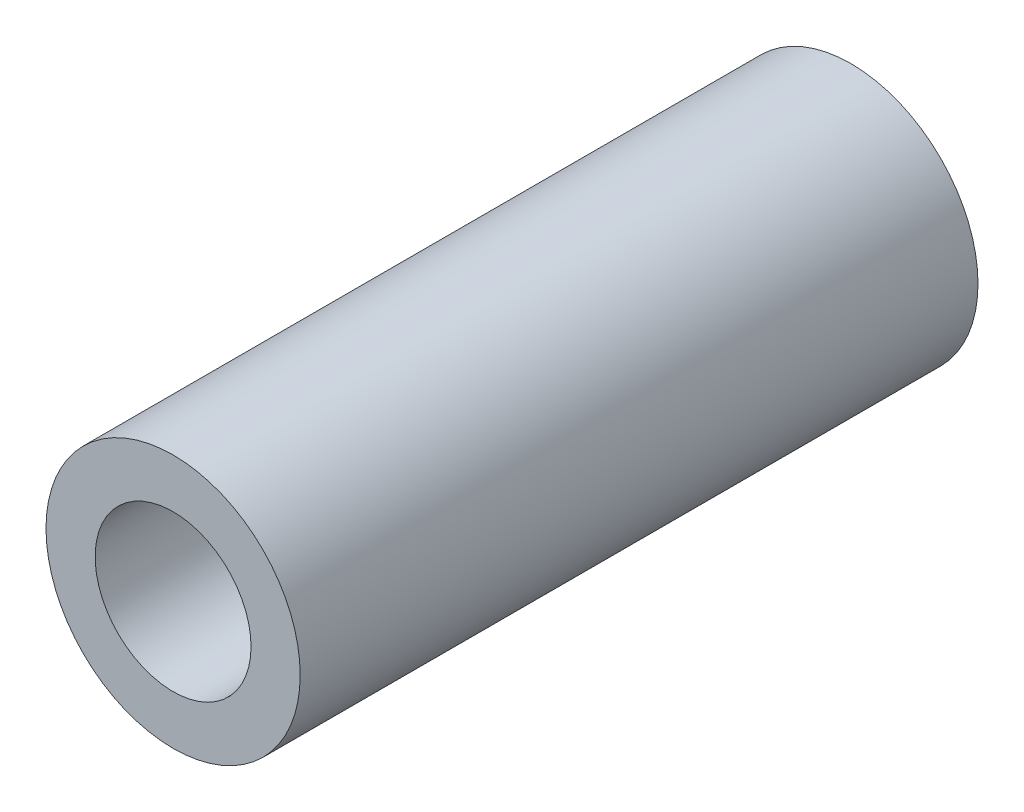
from build123d import *

# Parameters (mm, degrees)
SKETCH1_R           = 2.38125
SKETCH1_R_2         = 1.4605
EXTRUDE1_DEPTH      = 6.35
EXTRUDE1_DEPTH_BACK = 6.35


with BuildPart() as part:
    # Sketch1 → Extrude1 (new body, two sides)
    with BuildSketch(Plane.XY) as extrude1_sk:
        Circle(SKETCH1_R)
        Circle(SKETCH1_R_2, mode=Mode.SUBTRACT)
    extrude(amount=EXTRUDE1_DEPTH)
    extrude(extrude1_sk.sketch, amount=-EXTRUDE1_DEPTH_BACK)


solid = part.part
